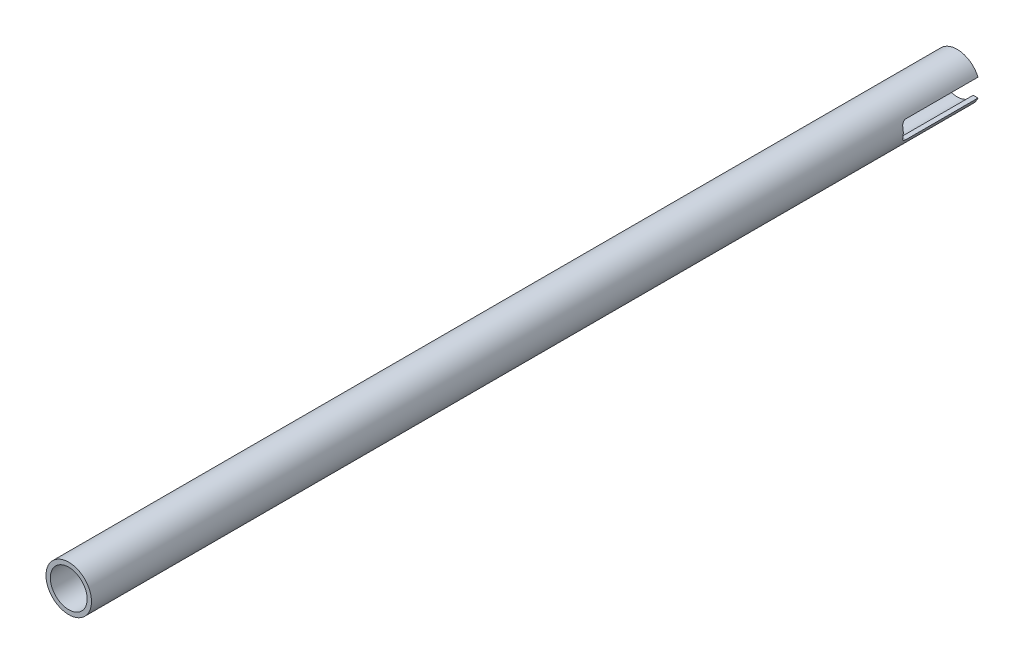
from build123d import *

# Parameters (mm, degrees)
SKETCH1_R               = 8.001
SKETCH1_R_2             = 6.477
BOSS_EXTRUDE1_DEPTH     = 312.42
CUT_EXTRUDE2_DEPTH      = 9.001
CUT_EXTRUDE2_DEPTH_BACK = 9.001


with BuildPart() as part:
    # Sketch1 → Boss-Extrude1 (new body)
    with BuildSketch(Plane.XY):
        Circle(SKETCH1_R)
        Circle(SKETCH1_R_2, mode=Mode.SUBTRACT)
    extrude(amount=BOSS_EXTRUDE1_DEPTH)

    # Sketch2 → Cut-Extrude2 (cut, two sides)
    with BuildSketch(Plane(origin=(0, 0, 0), x_dir=(0, 0, -1), z_dir=(1, 0, 0))) as cut_extrude2_sk:
        with BuildLine():
            Line((635.239664052, 3.175), (0, 3.175))
            Line((0, 3.175), (-25.4, 3.175))
            ThreePointArc((-25.4, 3.175), (-26.477630735, 2.728630735), (-26.924, 1.651))
            Line((-26.924, 1.651), (-26.924, -1.651))
            ThreePointArc((-26.924, -1.651), (-26.477630735, -2.728630735), (-25.4, -3.175))
            Line((-25.4, -3.175), (0, -3.175))
            Line((0, -3.175), (635.239664052, -3.175))
            Line((635.239664052, -3.175), (1905.718992156, -3.175))
            Line((1905.718992156, -3.175), (1905.718992156, 3.175))
            Line((1905.718992156, 3.175), (635.239664052, 3.175))
        make_face()
    extrude(amount=CUT_EXTRUDE2_DEPTH, mode=Mode.SUBTRACT)
    extrude(cut_extrude2_sk.sketch, amount=-CUT_EXTRUDE2_DEPTH_BACK, mode=Mode.SUBTRACT)


solid = part.part
